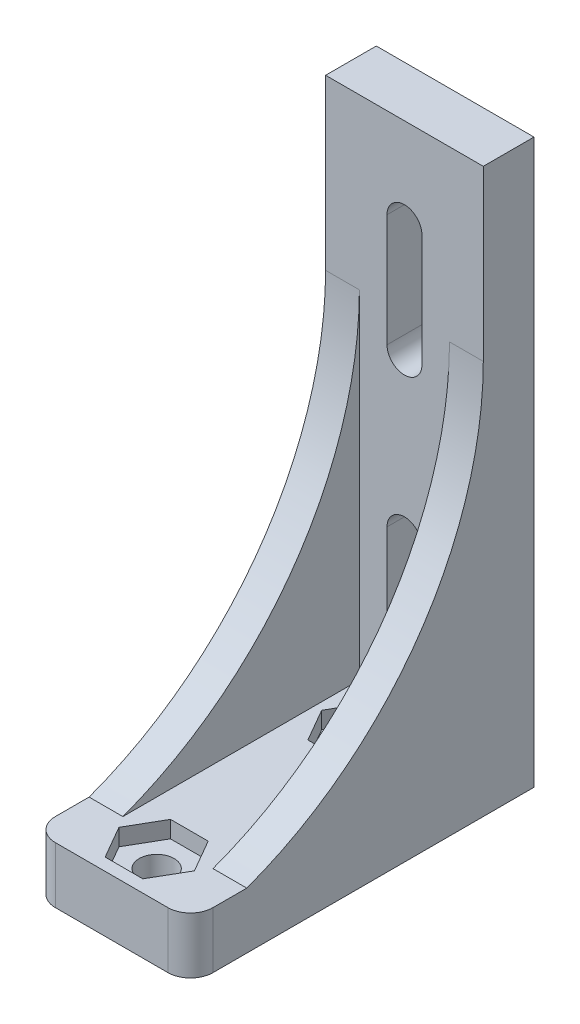
from build123d import *

# Parameters (mm, degrees)
CROQUIS2_W              = 14
CROQUIS2_H              = 31
CROQUIS2_R              = 1.55
SALIENTE_EXTRUIR1_DEPTH = 50
CROQUIS3_W              = 26
CROQUIS3_H              = 45
CORTAR_EXTRUIR1_DEPTH   = 14
CORTAR_EXTRUIR2_DEPTH   = 5
CORTAR_EXTRUIR3_DEPTH   = 1.5
SALIENTE_EXTRUIR3_DEPTH = 14
CROQUIS7_OUTSIDE_W      = 28.094
CROQUIS7_OUTSIDE_H      = 45.094
CORTAR_EXTRUIR5_DEPTH   = 45
REDONDEO1_R             = 2
CROQUIS8_W              = 14
CROQUIS8_H              = 0.5
CORTAR_EXTRUIR6_DEPTH   = 50


with BuildPart() as part:
    # Croquis2 → Saliente-Extruir1 (new body)
    with BuildSketch(Plane(origin=(0, 0, 0), x_dir=(1, 0, 0), z_dir=(0, 1, 0))):
        with Locations((7, 15.5)):
            Rectangle(CROQUIS2_W, CROQUIS2_H)
        with Locations((7, 22)):
            Circle(CROQUIS2_R, mode=Mode.SUBTRACT)
        with Locations((7, 4)):
            Circle(CROQUIS2_R, mode=Mode.SUBTRACT)
    extrude(amount=SALIENTE_EXTRUIR1_DEPTH)

    # Croquis3 → Cortar-Extruir1 (cut)
    with BuildSketch(Plane.ZY):
        with Locations((-13, 27.5)):
            Rectangle(CROQUIS3_W, CROQUIS3_H)
    extrude(amount=-CORTAR_EXTRUIR1_DEPTH, mode=Mode.SUBTRACT)

    # Croquis4 → Cortar-Extruir2 (cut)
    with BuildSketch(Plane(origin=(0, 0, -31), x_dir=(-1, 0, 0), z_dir=(0, 0, -1))):
        with BuildLine():
            Line((-8.55, 8), (-8.55, 18))
            ThreePointArc((-8.55, 18), (-7, 19.55), (-5.45, 18))
            Line((-5.45, 18), (-5.45, 8))
            ThreePointArc((-5.45, 8), (-7, 6.45), (-8.55, 8))
        make_face()
        with BuildLine():
            Line((-8.55, 32), (-8.55, 42))
            ThreePointArc((-8.55, 42), (-7, 43.55), (-5.45, 42))
            Line((-5.45, 42), (-5.45, 32))
            ThreePointArc((-5.45, 32), (-7, 30.45), (-8.55, 32))
        make_face()
    extrude(amount=-CORTAR_EXTRUIR2_DEPTH, mode=Mode.SUBTRACT)

    # Croquis5 → Cortar-Extruir3 (cut)
    with BuildSketch(Plane(origin=(0, 5, 0), x_dir=(1, 0, 0), z_dir=(0, 1, 0))):
        Polygon((10.348631561, 4), (8.674315781, 6.9), (5.325684219, 6.9), (3.651368439, 4), (5.325684219, 1.1), (8.674315781, 1.1), align=None)
        Polygon((8.674315781, 19.1), (10.348631561, 22), (8.674315781, 24.9), (5.325684219, 24.9), (3.651368439, 22), (5.325684219, 19.1), align=None)
    extrude(amount=-CORTAR_EXTRUIR3_DEPTH, mode=Mode.SUBTRACT)

    # Croquis6 → Saliente-Extruir3 (add)
    with BuildSketch(Plane.ZY):
        with BuildLine():
            Line((-26, 5), (-26, 35))
            ThreePointArc((-26, 35), (-20.21590319, 16.698867767), (-5, 5))
            Line((-5, 5), (-26, 5))
        make_face()
    extrude(amount=-SALIENTE_EXTRUIR3_DEPTH)

    # Croquis7 outside → Cortar-Extruir5 (cut)
    with BuildSketch(Plane(origin=(0, 50, 0), x_dir=(1, 0, 0), z_dir=(0, 1, 0))):
        with Locations((7, 15.5)):
            Rectangle(CROQUIS7_OUTSIDE_W, CROQUIS7_OUTSIDE_H)
        Polygon((0, 26), (0, 0), (3, 0), (3, 26), (11, 26), (11, 0), (14, 0), (14, 26), (14, 31), (0, 31), align=None, mode=Mode.SUBTRACT)
    extrude(amount=-CORTAR_EXTRUIR5_DEPTH, mode=Mode.SUBTRACT)

    # Redondeo1
    redondeo1_edges = [part.edges().sort_by_distance(p)[0] for p in [
        (14, 2.5, 0),
        (0, 2.5, 0),
    ]]
    fillet(redondeo1_edges, radius=REDONDEO1_R)

    # Croquis8 → Cortar-Extruir6 (cut)
    with BuildSketch(Plane(origin=(0, 50, 0), x_dir=(1, 0, 0), z_dir=(0, 1, 0))):
        with Locations((7, 30.75)):
            Rectangle(CROQUIS8_W, CROQUIS8_H)
    extrude(amount=-CORTAR_EXTRUIR6_DEPTH, mode=Mode.SUBTRACT)


solid = part.part
